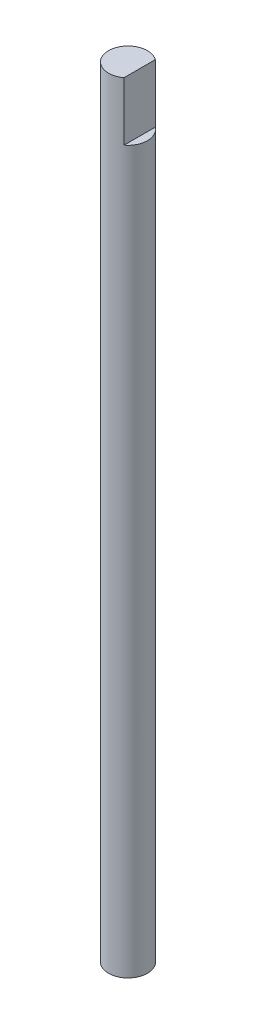
from build123d import *

# Parameters (mm, degrees)
SKETCH1_R       = 5
BASE_DEPTH      = 200
SKETCH2_W       = 2
SKETCH2_H       = 16.134958609
SLOT_DEPTH      = 6
SLOT_DEPTH_BACK = 6


with BuildPart() as part:
    # Sketch1 → Base (new body)
    with BuildSketch(Plane(origin=(0, 0, 0), x_dir=(1, 0, 0), z_dir=(0, 1, 0))):
        Circle(SKETCH1_R)
    extrude(amount=BASE_DEPTH)

    # Sketch2 → Slot (cut, two sides)
    with BuildSketch(Plane.XY) as slot_sk:
        with Locations((4, 193.067479305)):
            Rectangle(SKETCH2_W, SKETCH2_H)
    extrude(amount=SLOT_DEPTH, mode=Mode.SUBTRACT)
    extrude(slot_sk.sketch, amount=-SLOT_DEPTH_BACK, mode=Mode.SUBTRACT)


solid = part.part
